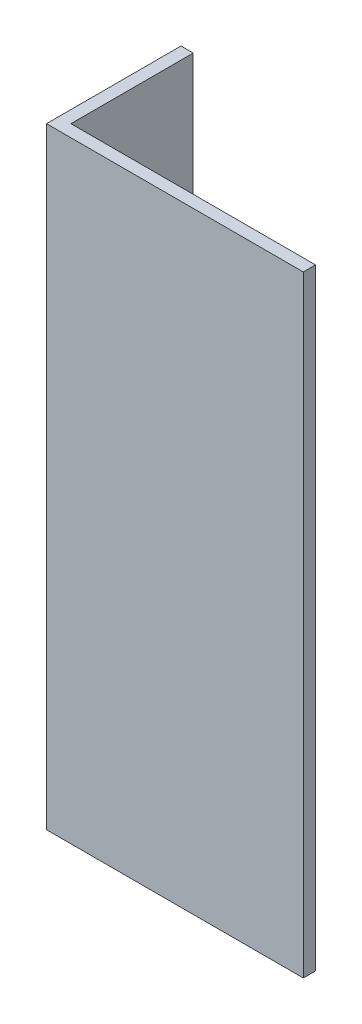
from build123d import *

# Parameters (mm, degrees)
BOSS_EXTRU_1_DEPTH = 50


with BuildPart() as part:
    # Esquisse1 → Boss.-Extru.1 (new body)
    with BuildSketch(Plane(origin=(0, 0, 0), x_dir=(1, 0, 0), z_dir=(0, 1, 0))):
        Polygon((-11, 9.5), (-11, -1.5), (10, -1.5), (10, -0.5), (-10, -0.5), (-10, 9.5), align=None)
    extrude(amount=BOSS_EXTRU_1_DEPTH)


solid = part.part
